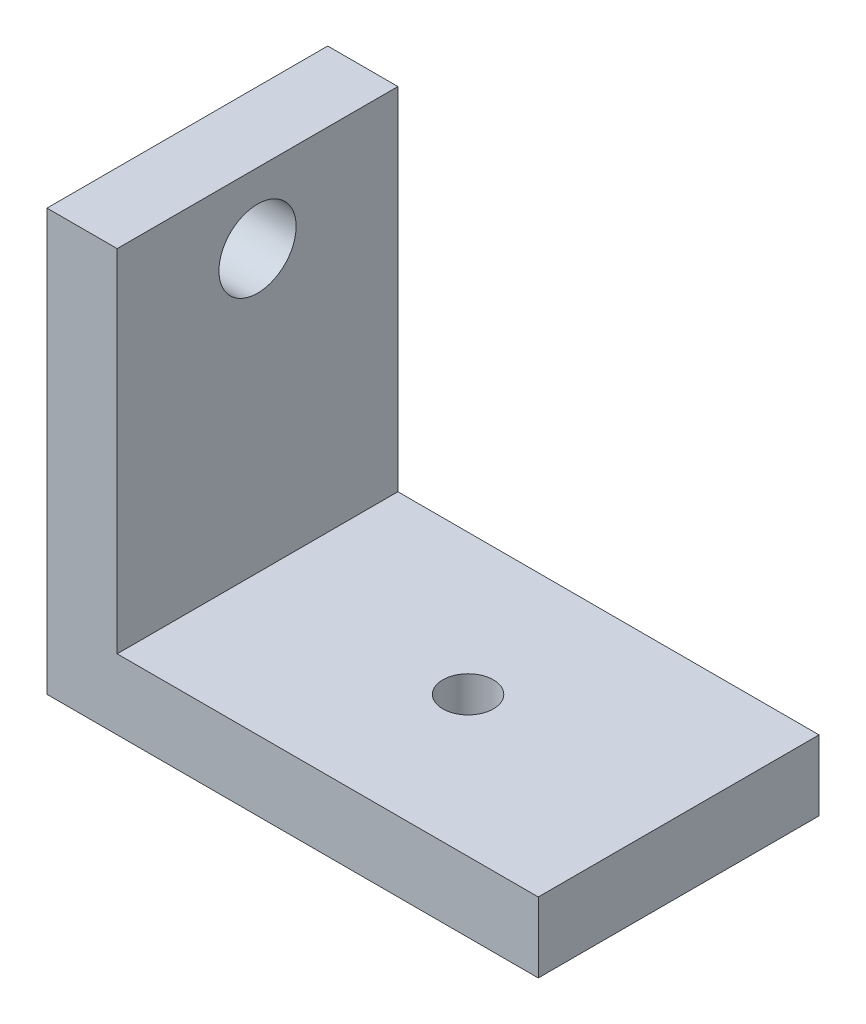
from build123d import *

# Parameters (mm, degrees)
SKETCH_5_W          = 20
SKETCH_5_H          = 30
SKETCH_5_R          = 2.75
EXTRUDE_1_DEPTH     = 5
SKETCH_6_W          = 20
SKETCH_6_H          = 5
EXTRUDE_2_DEPTH     = 30
SKETCH_7_R          = 1.8
CUT_EXTRUDE_1_DEPTH = 6


with BuildPart() as part:
    # 草图5 → 凸台-拉伸1 (new body)
    with BuildSketch(Plane(origin=(0, 0, 0), x_dir=(0, 0, -1), z_dir=(1, 0, 0))):
        Rectangle(SKETCH_5_W, SKETCH_5_H)
        with Locations((0, 10)):
            Circle(SKETCH_5_R, mode=Mode.SUBTRACT)
    extrude(amount=EXTRUDE_1_DEPTH)

    # 草图6 → 凸台-拉伸2 (add)
    with BuildSketch(Plane(origin=(5, 0, 0), x_dir=(0, 0, -1), z_dir=(1, 0, 0))):
        with Locations((0, -12.5)):
            Rectangle(SKETCH_6_W, SKETCH_6_H)
    extrude(amount=EXTRUDE_2_DEPTH)

    # 草图7 → 切除-拉伸1 (cut, through all)
    with BuildSketch(Plane(origin=(0, -10, 0), x_dir=(1, 0, 0), z_dir=(0, 1, 0))):
        with Locations((20, 0)):
            Circle(SKETCH_7_R)
    extrude(amount=-CUT_EXTRUDE_1_DEPTH, mode=Mode.SUBTRACT)


solid = part.part
